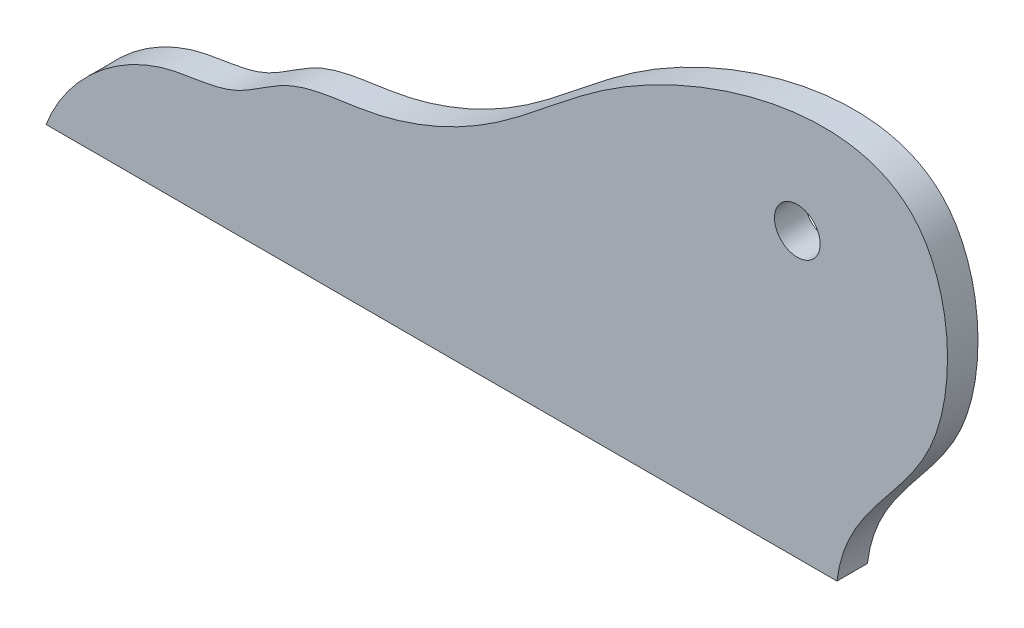
from build123d import *

# Parameters (mm, degrees)
SKETCH1_R           = 2.38125
BOSS_EXTRUDE1_DEPTH = 3.175


with BuildPart() as part:
    # Sketch1 → Boss-Extrude1 (new body)
    with BuildSketch(Plane.XY):
        with BuildLine():
            Line((320.529135655, 17.063190558), (402.953151444, 17.063190558))
            add(Edge.make_bspline(
                [(320.529135655, 17.063190558), (322.602747372, 22.422070846), (329.56943156, 28.803323221), (340.18186162, 29.102699295), (346.034342646, 34.28982774), (356.087217077, 34.66657494), (368.371006485, 40.242236287), (381.865472251, 53.862140686), (414.277353483, 63.701732451), (415.988761744, 31.299570063), (403.823403651, 24.424378095), (402.953151444, 17.063190558)],
                knots=[0, 0, 0, 0, 0.124039971, 0.172265538, 0.219743728, 0.281542584, 0.380522413, 0.496240551, 0.718660308, 0.860484876, 1, 1, 1, 1], degree=3))
        make_face()
        with Locations((398.821621831, 46.603627294)):
            Circle(SKETCH1_R, mode=Mode.SUBTRACT)
    extrude(amount=BOSS_EXTRUDE1_DEPTH)


solid = part.part
